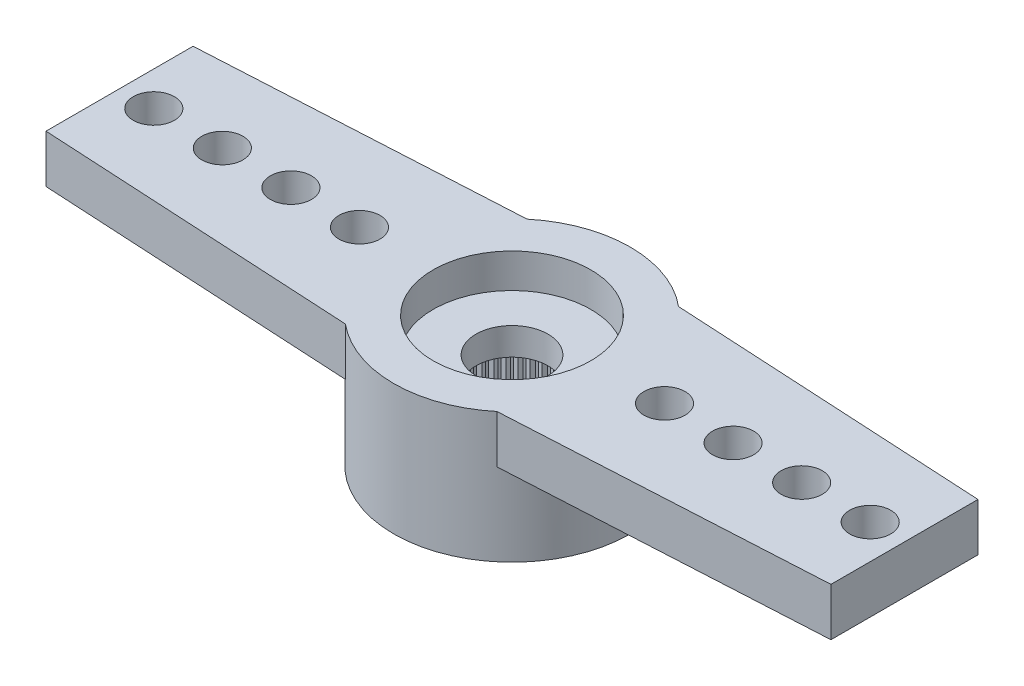
from build123d import *

# Parameters (mm, degrees)
RESSALTO_EXTRUS_O1_DEPTH = 1.4
ESBO_O2_R                = 3.45
RESSALTO_EXTRUS_O2_DEPTH = 2.4
FURO4_D                  = 1.2
PADR_O_LINEAR1_COUNT     = 6
PADR_O_LINEAR1_PITCH     = 2
PADR_OCIRCULAR2_COUNT    = 2
PADR_OCIRCULAR2_COPY_1_D = 1.2
PADR_OCIRCULAR2_COPY_2_D = 1.2
PADR_OCIRCULAR2_COPY_3_D = 1.2
PADR_OCIRCULAR2_COPY_4_D = 1.2
PADR_OCIRCULAR2_COPY_5_D = 1.2
FURO1_D                  = 4.95
FURO1_DEPTH              = 2
FURO2_D                  = 4.6
FURO2_DEPTH              = 1
FURO3_D                  = 2.1
RESSALTO_EXTRUS_O3_DEPTH = 2
PADR_OCIRCULAR1_COUNT    = 60
CUT_EXTRUDE2_DEPTH       = 10


with BuildPart() as part:
    # Esboço1 → Ressalto-extrusão1 (new body)
    with BuildSketch(Plane(origin=(0, 0, 0), x_dir=(1, 0, 0), z_dir=(0, 1, 0))):
        with BuildLine():
            Line((-14.159121967, 1.99702088), (-2.209072203, 2.65))
            ThreePointArc((-2.209072203, 2.65), (3.45, 0), (-2.209072203, -2.65))
            Line((-2.209072203, -2.65), (-14.159121967, -1.99702088))
            ThreePointArc((-14.159121967, -1.99702088), (-16.05, 0), (-14.159121967, 1.99702088))
        make_face()
    ressalto_extrus_o1 = extrude(amount=-RESSALTO_EXTRUS_O1_DEPTH)

    # Esboço2 → Ressalto-extrusão2 (add)
    with BuildSketch(Plane.XZ.offset(1.4)):
        Circle(ESBO_O2_R)
    extrude(amount=RESSALTO_EXTRUS_O2_DEPTH)

    # Furo4 (through all)
    with Locations(Plane(origin=(0, 0, 0), x_dir=(1, 0, 0), z_dir=(0, 1, 0))):
        with Locations((-14.45, 0)):
            furo4 = Hole(FURO4_D / 2)

    # Padrão linear1: Furo4 ×6
    with Locations(*[(i * PADR_O_LINEAR1_PITCH, 0, 0) for i in range(1, PADR_O_LINEAR1_COUNT)]):
        add(furo4, mode=Mode.SUBTRACT)

    # PadrãoCircular2: Ressalto-extrusão1, Furo4 ×2 about axis
    padr_ocircular2_axis = Axis((0, 0, 0), (0, 1, 0))
    for i in range(1, PADR_OCIRCULAR2_COUNT):
        add(ressalto_extrus_o1.rotate(padr_ocircular2_axis, i * 360 / PADR_OCIRCULAR2_COUNT))
        add(furo4.rotate(padr_ocircular2_axis, i * 360 / PADR_OCIRCULAR2_COUNT), mode=Mode.SUBTRACT)

    # PadrãoCircular2 copy 1 (through all)
    with Locations(Plane(origin=(-2, 0, 0), x_dir=(-1, 0, 0), z_dir=(0, 1, 0))):
        with Locations((-14.45, 0)):
            Hole(PADR_OCIRCULAR2_COPY_1_D / 2)

    # PadrãoCircular2 copy 2 (through all)
    with Locations(Plane(origin=(-4, 0, 0), x_dir=(-1, 0, 0), z_dir=(0, 1, 0))):
        with Locations((-14.45, 0)):
            Hole(PADR_OCIRCULAR2_COPY_2_D / 2)

    # PadrãoCircular2 copy 3 (through all)
    with Locations(Plane(origin=(-6, 0, 0), x_dir=(-1, 0, 0), z_dir=(0, 1, 0))):
        with Locations((-14.45, 0)):
            Hole(PADR_OCIRCULAR2_COPY_3_D / 2)

    # PadrãoCircular2 copy 4 (through all)
    with Locations(Plane(origin=(-8, 0, 0), x_dir=(-1, 0, 0), z_dir=(0, 1, 0))):
        with Locations((-14.45, 0)):
            Hole(PADR_OCIRCULAR2_COPY_4_D / 2)

    # PadrãoCircular2 copy 5 (through all)
    with Locations(Plane(origin=(-10, 0, 0), x_dir=(-1, 0, 0), z_dir=(0, 1, 0))):
        with Locations((-14.45, 0)):
            Hole(PADR_OCIRCULAR2_COPY_5_D / 2)

    # Furo1
    with Locations(Plane(origin=(0, -3.8, 0), x_dir=(-1, 0, 0), z_dir=(0, -1, 0))):
        with Locations((0, 0)):
            Hole(FURO1_D / 2, depth=FURO1_DEPTH)

    # Furo2
    with Locations(Plane(origin=(0, 0, 0), x_dir=(1, 0, 0), z_dir=(0, 1, 0))):
        with Locations((0, 0)):
            Hole(FURO2_D / 2, depth=FURO2_DEPTH)

    # Furo3 (through all)
    with Locations(Plane(origin=(0, 0, 0), x_dir=(1, 0, 0), z_dir=(0, 1, 0))):
        with Locations((0, 0)):
            Hole(FURO3_D / 2)

    # Esboço11 → Ressalto-extrusão3 (add)
    with BuildSketch(Plane.XZ.offset(3.8)):
        with BuildLine():
            Line((-0.098056786, 2.473056786), (0, 2.375))
            Line((0, 2.375), (0.098056786, 2.473056786))
            ThreePointArc((0.098056786, 2.473056786), (0, 2.475), (-0.098056786, 2.473056786))
        make_face()
    ressalto_extrus_o3 = extrude(amount=-RESSALTO_EXTRUS_O3_DEPTH)

    # PadrãoCircular1: Ressalto-extrusão3 ×60 about axis
    padr_ocircular1_axis = Axis((0, 0, 0), (0, 1, 0))
    for i in range(1, PADR_OCIRCULAR1_COUNT):
        add(ressalto_extrus_o3.rotate(padr_ocircular1_axis, i * 360 / PADR_OCIRCULAR1_COUNT))

    # Sketch2 → Cut-Extrude2 (cut)
    with BuildSketch(Plane(origin=(0, 0, 0), x_dir=(1, 0, 0), z_dir=(0, 1, 0))):
        with BuildLine():
            ThreePointArc((14.159121967, -1.99702088), (15.502281642, -1.375092009), (16.05, 0))
            Line((16.05, 0), (15.05, 0))
            ThreePointArc((15.05, 0), (14.45, -0.6), (13.85, 0))
            Line((13.85, 0), (13.05, 0))
            ThreePointArc((13.05, 0), (12.45, -0.6), (11.85, 0))
            Line((11.85, 0), (11.45, 0))
            Line((11.45, 0), (11.45, -2.145053743))
            Line((11.45, -2.145053743), (14.159121967, -1.99702088))
        make_face()
        with BuildLine():
            Line((-14.159121967, 1.99702088), (-11.45, 2.145053743))
            Line((-11.45, 2.145053743), (-17.501372269, 2.145053743))
            Line((-17.501372269, 2.145053743), (-18.074774731, -1.783060307))
            Line((-18.074774731, -1.783060307), (-14.159121967, -1.99702088))
            ThreePointArc((-14.159121967, -1.99702088), (-15.502281642, -1.375092009), (-16.05, 0))
            ThreePointArc((-16.05, 0), (-15.502281642, 1.375092009), (-14.159121967, 1.99702088))
        make_face()
        with BuildLine():
            Line((-11.85, 0), (-11.45, 0))
            Line((-11.45, 0), (-11.45, 2.145053743))
            Line((-11.45, 2.145053743), (-14.159121967, 1.99702088))
            ThreePointArc((-14.159121967, 1.99702088), (-15.502281642, 1.375092009), (-16.05, 0))
            Line((-16.05, 0), (-15.05, 0))
            ThreePointArc((-15.05, 0), (-14.45, 0.6), (-13.85, 0))
            Line((-13.85, 0), (-13.05, 0))
            ThreePointArc((-13.05, 0), (-12.45, 0.6), (-11.85, 0))
        make_face()
        with BuildLine():
            Line((-11.45, -2.145053743), (-11.45, 0))
            Line((-11.45, 0), (-11.85, 0))
            ThreePointArc((-11.85, 0), (-12.45, -0.6), (-13.05, 0))
            Line((-13.05, 0), (-13.85, 0))
            ThreePointArc((-13.85, 0), (-14.45, -0.6), (-15.05, 0))
            Line((-15.05, 0), (-16.05, 0))
            ThreePointArc((-16.05, 0), (-15.502281642, -1.375092009), (-14.159121967, -1.99702088))
            Line((-14.159121967, -1.99702088), (-11.45, -2.145053743))
        make_face()
        with BuildLine():
            Line((15.05, 0), (16.05, 0))
            ThreePointArc((16.05, 0), (15.502281642, 1.375092009), (14.159121967, 1.99702088))
            Line((14.159121967, 1.99702088), (11.45, 2.145053743))
            Line((11.45, 2.145053743), (11.45, 0))
            Line((11.45, 0), (11.85, 0))
            ThreePointArc((11.85, 0), (12.45, 0.6), (13.05, 0))
            Line((13.05, 0), (13.85, 0))
            ThreePointArc((13.85, 0), (14.45, 0.6), (15.05, 0))
        make_face()
    extrude(amount=-CUT_EXTRUDE2_DEPTH, mode=Mode.SUBTRACT)


solid = part.part
